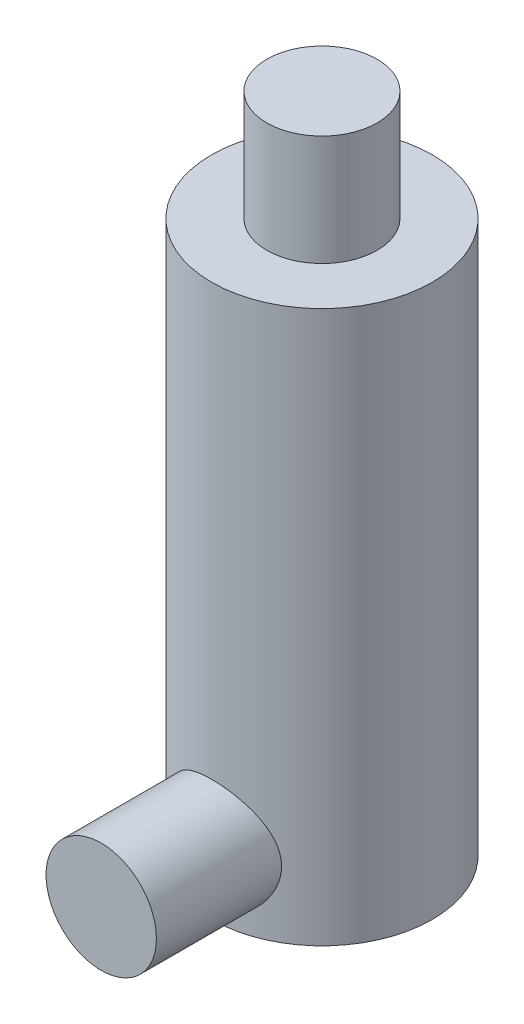
from build123d import *

# Parameters (mm, degrees)
SKETCH1_R                       = 5
BOSS_EXTRUDE1_DEPTH             = 25
SKETCH2_R                       = 2.5
BOSS_EXTRUDE2_DEPTH             = 5
BOSS_EXTRUDE2_DIRECTION_2_REACH = 12
SKETCH4_R                       = 2.5
BOSS_EXTRUDE3_DEPTH             = 5


with BuildPart() as part:
    # Sketch1 → Boss-Extrude1 (new body)
    with BuildSketch(Plane(origin=(0, 0, 0), x_dir=(1, 0, 0), z_dir=(0, 1, 0))):
        Circle(SKETCH1_R)
    extrude(amount=BOSS_EXTRUDE1_DEPTH)


with BuildPart() as body_2:
    # Sketch2 → Boss-Extrude2 (new body)
    with BuildSketch(Plane.XY.offset(5)):
        with Locations((0, 3)):
            Circle(SKETCH2_R)
    extrude(amount=BOSS_EXTRUDE2_DEPTH)


    # Sketch2 → Boss-Extrude2 direction 2 (add, up to next)
    with BuildSketch(Plane.XY.offset(5), mode=Mode.PRIVATE) as boss_extrude2_direction_2_sk1:
        with Locations((0, 3)):
            Circle(SKETCH2_R)
    boss_extrude2_direction_2_tool1 = extrude(boss_extrude2_direction_2_sk1.sketch, amount=-BOSS_EXTRUDE2_DIRECTION_2_REACH, mode=Mode.PRIVATE) - part.part
    add(boss_extrude2_direction_2_tool1.solids().sort_by_distance((0, 3, 5))[0])
    add(boss_extrude2_direction_2_tool1.solids().sort_by_distance((0, 3, 5))[1])


with BuildPart() as part_1:
    add(part.part)

    # Sketch4 → Boss-Extrude3 (add)
    with BuildSketch(Plane(origin=(0, 25, 0), x_dir=(1, 0, 0), z_dir=(0, 1, 0))):
        Circle(SKETCH4_R)
    extrude(amount=BOSS_EXTRUDE3_DEPTH)


solid = Compound([body_2.part, part_1.part])
